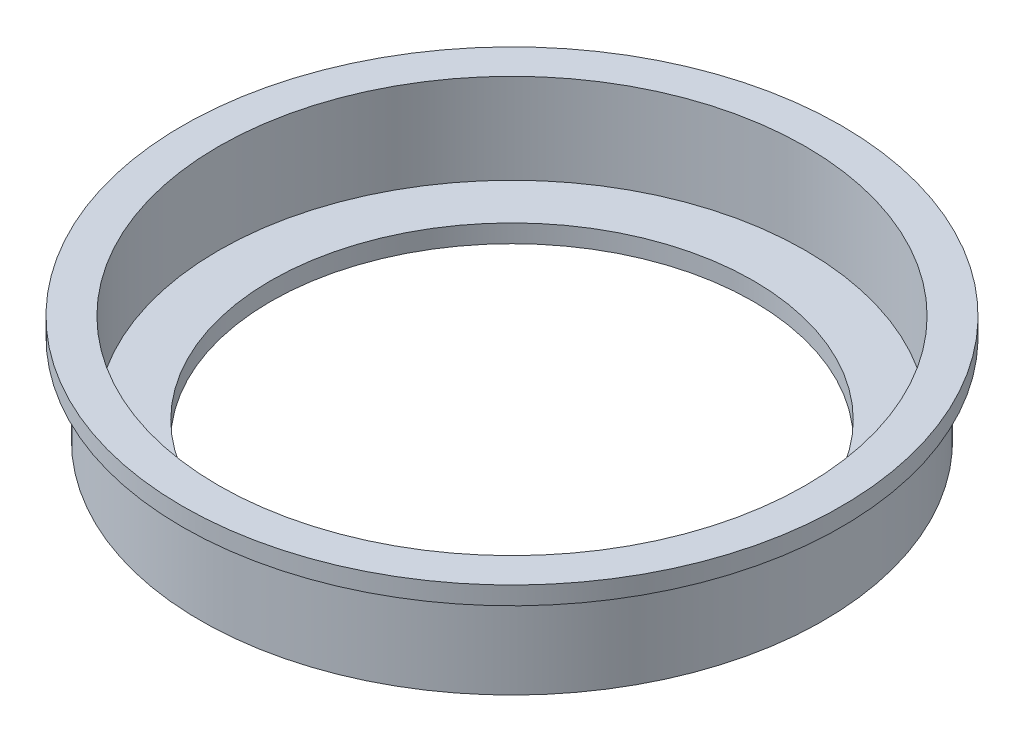
from build123d import *


with BuildPart() as part:
    # Sketch1 → Revolve1 (revolve)
    with BuildSketch(Plane.XY):
        Polygon((34.036, 0), (34.036, 2.54), (41.402, 2.54), (41.402, 15.24), (46.482, 15.24), (46.482, 12.7), (43.942, 12.7), (43.942, 0), align=None)
    revolve(axis=Axis((0, 0, 0), (0, 1, 0)))


solid = part.part
